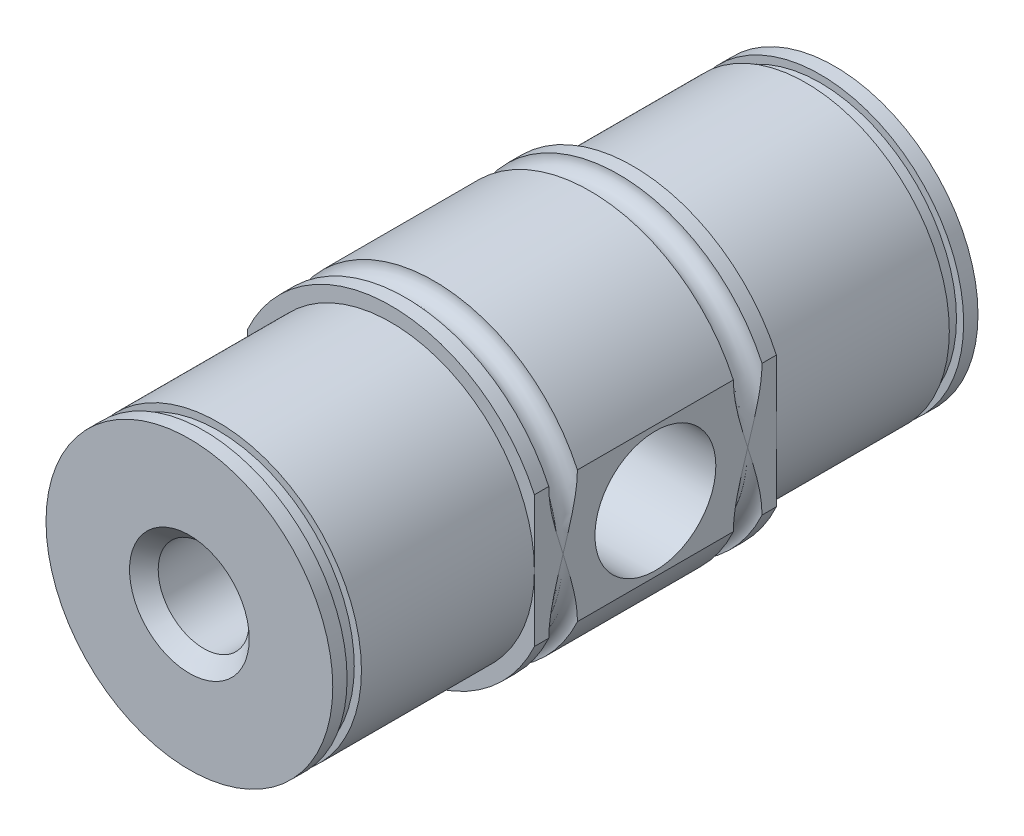
from build123d import *

# Parameters (mm, degrees)
SKETCH1_R               = 11
BOSS_EXTRUDE1_DEPTH     = 16.875
SKETCH2_R               = 10
BOSS_EXTRUDE2_DEPTH     = 14.0625
SKETCH3_R               = 10
BOSS_EXTRUDE3_DEPTH     = 14.0625
CUT_EXTRUDE4_DEPTH      = 15.0625
CUT_EXTRUDE4_DEPTH_BACK = 31.9375
SKETCH6_W               = 1
SKETCH6_H               = 0.5
F_3_8_24_TAPPED_HOLE1_D = 8.4328
SKETCH10_R              = 3.175
CUT_EXTRUDE5_DEPTH      = 1
CUT_EXTRUDE5_DEPTH_BACK = 46
CHAMFER1_SIZE           = 1


with BuildPart() as part:
    # Sketch1 → Boss-Extrude1 (new body)
    with BuildSketch(Plane.XY):
        Circle(SKETCH1_R)
    extrude(amount=BOSS_EXTRUDE1_DEPTH)

    # Sketch2 → Boss-Extrude2 (add)
    with BuildSketch(Plane(origin=(0, 0, 0), x_dir=(-1, 0, 0), z_dir=(0, 0, -1))):
        Circle(SKETCH2_R)
    extrude(amount=BOSS_EXTRUDE2_DEPTH)

    # Sketch3 → Boss-Extrude3 (add)
    with BuildSketch(Plane.XY.offset(16.875)):
        Circle(SKETCH3_R)
    extrude(amount=BOSS_EXTRUDE3_DEPTH)

    # Sketch5 → Cut-Extrude4 (cut, two sides)
    with BuildSketch(Plane(origin=(0, 0, 0), x_dir=(-1, 0, 0), z_dir=(0, 0, -1))) as cut_extrude4_sk:
        with BuildLine():
            Line((-10, -4.582575695), (-10, 4.582575695))
            ThreePointArc((-10, 4.582575695), (-11, 0), (-10, -4.582575695))
        make_face()
        with BuildLine():
            ThreePointArc((11, 0), (10.74709263, 2.34520788), (10, 4.582575695))
            Line((10, 4.582575695), (10, -4.582575695))
            ThreePointArc((10, -4.582575695), (10.74709263, -2.34520788), (11, 0))
        make_face()
    extrude(amount=CUT_EXTRUDE4_DEPTH, mode=Mode.SUBTRACT)
    extrude(cut_extrude4_sk.sketch, amount=-CUT_EXTRUDE4_DEPTH_BACK, mode=Mode.SUBTRACT)

    # Sketch6 → Cut-Revolve1 (revolve, cut)
    with BuildSketch(Plane(origin=(0, 0, 0), x_dir=(0, 0, -1), z_dir=(1, 0, 0))):
        with Locations((12.5625, 9.75)):
            Rectangle(SKETCH6_W, SKETCH6_H)
        with BuildLine():
            Line((-15.875, 11), (-13.875, 11))
            ThreePointArc((-13.875, 11), (-14.875, 10), (-15.875, 11))
        make_face()
        with Locations((-29.4375, 9.75)):
            Rectangle(SKETCH6_W, SKETCH6_H)
        with BuildLine():
            Line((-3, 11), (-1, 11))
            ThreePointArc((-1, 11), (-2, 10), (-3, 11))
        make_face()
    revolve(axis=Axis((0, 0, 30.9375), (0, 0, -1)), mode=Mode.SUBTRACT)

    # 3/8-24 Tapped Hole1 (through all)
    with Locations(Plane(origin=(10, 0, 0), x_dir=(0, 0, -1), z_dir=(1, 0, 0))):
        with Locations((-8.4375, 0)):
            Hole(F_3_8_24_TAPPED_HOLE1_D / 2)

    # Sketch10 → Cut-Extrude5 (cut, two sides)
    with BuildSketch(Plane(origin=(0, 0, -14.0625), x_dir=(-1, 0, 0), z_dir=(0, 0, -1))) as cut_extrude5_sk:
        Circle(SKETCH10_R)
    extrude(amount=CUT_EXTRUDE5_DEPTH, mode=Mode.SUBTRACT)
    extrude(cut_extrude5_sk.sketch, amount=-CUT_EXTRUDE5_DEPTH_BACK, mode=Mode.SUBTRACT)

    # Chamfer1
    chamfer1_edges = [part.edges().sort_by_distance(p)[0] for p in [
        (3.175, 0, -14.0625),
        (3.175, 0, 30.9375),
    ]]
    chamfer(chamfer1_edges, length=CHAMFER1_SIZE)


solid = part.part
